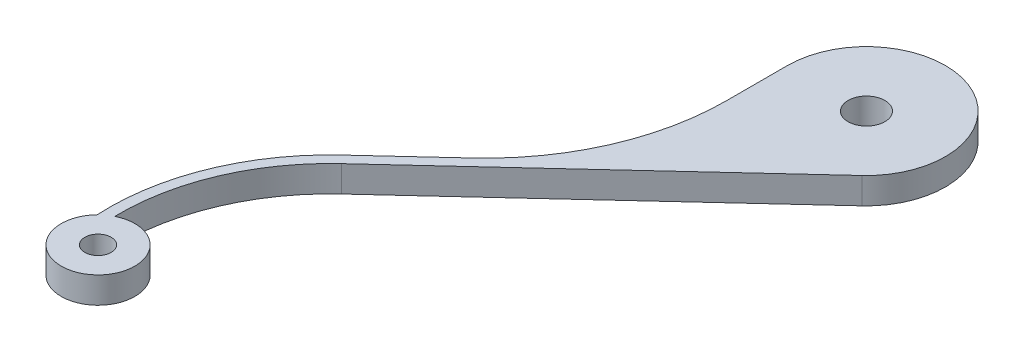
from build123d import *

# Parameters (mm, degrees)
ESQUISSE1_R      = 3.5
ESQUISSE1_R_2    = 2.5
EXTRUSION1_DEPTH = 5


with BuildPart() as part:
    # Esquisse1 → Extrusion1 (new body)
    with BuildSketch(Plane(origin=(0, 0, 0), x_dir=(1, 0, 0), z_dir=(0, 1, 0))):
        with BuildLine():
            Line((10.180478804, -11.016253961), (-41.228706345, -58.525155046))
            ThreePointArc((-41.228706345, -58.525155046), (-50.88895895, -72.244351595), (-54.072422177, -88.71864661))
            ThreePointArc((-54.072422177, -88.71864661), (-46.857537983, -100.655144285), (-56.021074344, -90.140196256))
            ThreePointArc((-56.021074344, -90.140196256), (-52.994554425, -72.099401237), (-42.586103519, -57.056321184))
            Line((-42.586103519, -57.056321184), (-29.72073238, -45.167013017))
            ThreePointArc((-29.72073238, -45.167013017), (-18.841206309, -29.882608736), (-15, -11.518997003))
            Line((-15, -11.518997003), (-15, 0))
            ThreePointArc((-15, 0), (6.012188368, 13.74240121), (10.180478804, -11.016253961))
        make_face()
        Circle(ESQUISSE1_R, mode=Mode.SUBTRACT)
        with Locations((-50.982988639, -95)):
            Circle(ESQUISSE1_R_2, mode=Mode.SUBTRACT)
    extrude(amount=EXTRUSION1_DEPTH)


solid = part.part
